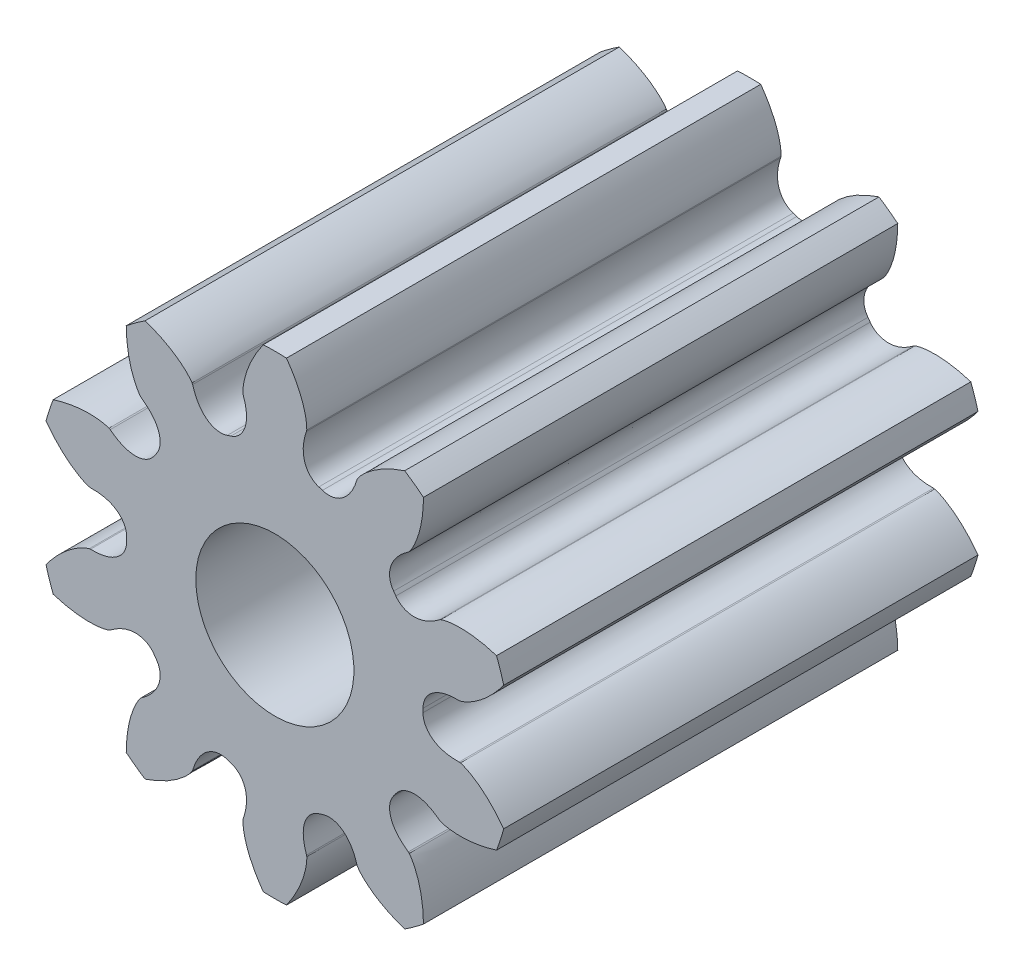
from build123d import *

# Parameters (mm, degrees)
TOOTH_DEPTH        = 6
TEETH_COUNT        = 10
SKETCH6_OUTSIDE_W  = 10.17
SKETCH6_OUTSIDE_H  = 10.48
SKETCH6_OUTSIDE_R  = 3
ADDENDUM_DEPTH     = 8.431505035
SKETCH8_R          = 1
CUT_EXTRUDE1_DEPTH = 8.3062853


with BuildPart() as part:
    # Sketch1 → Tooth (new body)
    with BuildSketch(Plane.XY):
        with BuildLine():
            Line((0.403833302, 2.337025202), (0.400760991, 2.320943747))
            add(Edge.make_bspline(
                [(0.400760991, 2.320943747), (0.386673551, 2.282139235), (0.370069341, 2.223430174), (0.359481749, 2.144320545), (0.357870732, 2.087044818), (0.363123959, 2.030301784), (0.376565354, 1.973817059), (0.40038547, 1.917902908), (0.451390546, 1.844336469), (0.51072073, 1.804476148), (0.556407001, 1.79054077)],
                knots=[0, 0, 0, 0, 0.20012551, 0.294348356, 0.386167986, 0.477231396, 0.569745357, 0.666449872, 0.770112617, 1, 1, 1, 1], degree=3))
            ThreePointArc((0.556407001, 1.79054077), (0, -1.875), (-0.556407001, 1.79054077))
            add(Edge.make_bspline(
                [(-0.400760991, 2.320943747), (-0.386673551, 2.282139235), (-0.370069341, 2.223430174), (-0.359481749, 2.144320545), (-0.357870732, 2.087044818), (-0.363123959, 2.030301784), (-0.376565354, 1.973817059), (-0.40038547, 1.917902908), (-0.451390546, 1.844336469), (-0.51072073, 1.804476148), (-0.556407001, 1.79054077)],
                knots=[0, 0, 0, 0, 0.20012551, 0.294348356, 0.386167986, 0.477231396, 0.569745357, 0.666449872, 0.770112617, 1, 1, 1, 1], degree=3))
            Line((-0.400760991, 2.320943747), (-0.403833302, 2.337025202))
            add(Edge.make_bspline(
                [(0, 3.177366371), (-0.067819183, 3.102854424), (-0.157523521, 2.989367158), (-0.252839345, 2.833104429), (-0.305563716, 2.729496796), (-0.344795573, 2.635088219), (-0.37229532, 2.551266676), (-0.389966802, 2.479197642), (-0.401521371, 2.409250483), (-0.404588452, 2.363118477), (-0.403833302, 2.337025202)],
                knots=[0, 0, 0, 0, 0.317753817, 0.454551878, 0.576630709, 0.683990311, 0.776630686, 0.854551835, 0.917753763, 1, 1, 1, 1], degree=3))
            add(Edge.make_bspline(
                [(0, 3.177366371), (0.067819183, 3.102854424), (0.157523521, 2.989367158), (0.252839345, 2.833104429), (0.305563716, 2.729496796), (0.344795573, 2.635088219), (0.37229532, 2.551266676), (0.389966802, 2.479197642), (0.401521371, 2.409250483), (0.404588452, 2.363118477), (0.403833302, 2.337025202)],
                knots=[0, 0, 0, 0, 0.317753817, 0.454551878, 0.576630709, 0.683990311, 0.776630686, 0.854551835, 0.917753763, 1, 1, 1, 1], degree=3))
        make_face()
    tooth = extrude(amount=TOOTH_DEPTH)

    # Teeth: Tooth ×10 about axis
    teeth_axis = Axis((0, 0, 6), (0, 0, -1))
    for i in range(1, TEETH_COUNT):
        add(tooth.rotate(teeth_axis, i * 360 / TEETH_COUNT))

    # Sketch6 outside → Addendum (cut, through all)
    with BuildSketch(Plane.XY):
        Rectangle(SKETCH6_OUTSIDE_W, SKETCH6_OUTSIDE_H)
        Circle(SKETCH6_OUTSIDE_R, mode=Mode.SUBTRACT)
    extrude(amount=ADDENDUM_DEPTH, mode=Mode.SUBTRACT)

    # Sketch8 → Cut-Extrude1 (cut, through all)
    with BuildSketch(Plane(origin=(0, 0, 0), x_dir=(-1, 0, 0), z_dir=(0, 0, -1))):
        Circle(SKETCH8_R)
    extrude(amount=-CUT_EXTRUDE1_DEPTH, mode=Mode.SUBTRACT)


solid = part.part
